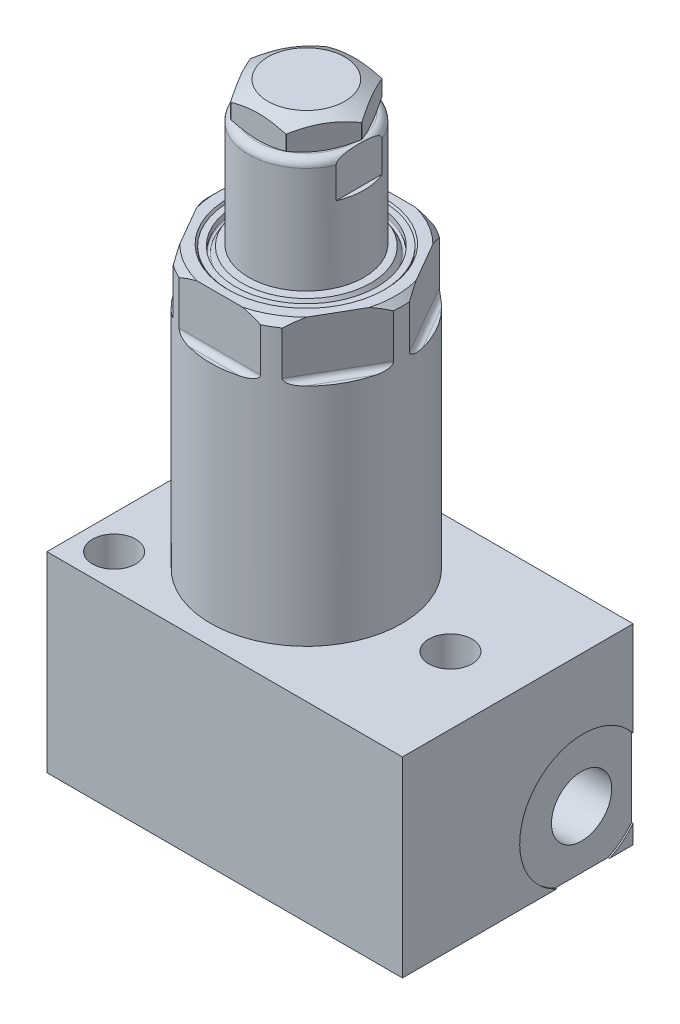
from build123d import *

# Parameters (mm, degrees)
SKETCH2_OUTSIDE_W   = 49.918
SKETCH2_OUTSIDE_H   = 49.918
CUT_EXTRUDE1_DEPTH  = 9.144
FILLET1_R           = 0.9144
SKETCH4_W           = 0.79375
SKETCH4_H           = 6.35
CUT_EXTRUDE2_DEPTH  = 11.1125
SKETCH5_W           = 4.6736
SKETCH5_H           = 6.35
SKETCH8_OUTSIDE_W   = 54.03
SKETCH8_OUTSIDE_H   = 54.03
CUT_EXTRUDE3_DEPTH  = 4.7752
SKETCH9_W           = 58.7248
SKETCH9_H           = 31.623
BOSS_EXTRUDE1_DEPTH = 19.05
SKETCH10_R          = 3.5687
CUT_EXTRUDE4_DEPTH  = 38.1
SKETCH11_R          = 10.4775
CUT_EXTRUDE5_DEPTH  = 0.254
SKETCH12_R          = 4.9784
CUT_EXTRUDE6_DEPTH  = 8.89
SKETCH14_R          = 7.9375
CUT_EXTRUDE7_DEPTH  = 2.667
SKETCH15_R          = 3.4544
CUT_EXTRUDE8_DEPTH  = 10.0076


with BuildPart() as part:
    # Sketch1 → Revolve1 (revolve)
    with BuildSketch(Plane.XY):
        with BuildLine():
            Line((9.4615, 0), (10.5918, 0))
            Line((10.5918, 0), (10.9728, 0.381))
            Line((10.9728, 0.381), (14.1097, 0.381))
            Line((14.1097, 0.381), (14.8717, 1.143))
            Line((14.8717, 1.143), (14.8717, 8.3058))
            Line((14.8717, 8.3058), (15.7988, 9.2329))
            Line((15.7988, 9.2329), (15.7988, 66.802))
            Line((15.7988, 66.802), (14.7828, 67.818))
            Line((14.7828, 67.818), (12.993293937, 67.818))
            Line((12.993293937, 67.818), (12.7, 67.31))
            Line((12.7, 67.31), (12.7, 67.5386))
            Line((12.7, 67.5386), (11.684, 67.5386))
            Line((11.684, 67.5386), (11.684, 66.6496))
            ThreePointArc((11.684, 66.6496), (11.495740037, 66.40425484), (11.210029547, 66.5226))
            Line((11.210029547, 66.5226), (10.623441674, 67.5386))
            Line((10.623441674, 67.5386), (0, 67.5386))
            Line((0, 67.5386), (0, 5.1308))
            Line((0, 5.1308), (2.3876, 5.1308))
            Line((2.3876, 5.1308), (2.3876, 1.3208))
            Line((2.3876, 1.3208), (8.5725, 1.3208))
            ThreePointArc((8.5725, 1.3208), (7.943882072, -0.196817928), (9.4615, 0.4318))
            Line((9.4615, 0.4318), (9.4615, 0))
        make_face()
    revolve(axis=Axis((0, 0, 0), (0, 1, 0)))

    # Sketch2 outside → Cut-Extrude1 (cut)
    with BuildSketch(Plane(origin=(0, 67.818, 0), x_dir=(1, 0, 0), z_dir=(0, 1, 0))):
        Rectangle(SKETCH2_OUTSIDE_W, SKETCH2_OUTSIDE_H)
        Polygon((16.497783942, 0), (8.248891971, 14.2875), (-8.248891971, 14.2875), (-16.497783942, 0), (-8.248891971, -14.2875), (8.248891971, -14.2875), align=None, mode=Mode.SUBTRACT)
    extrude(amount=-CUT_EXTRUDE1_DEPTH, mode=Mode.SUBTRACT)

    # Fillet1
    fillet1_edges = [part.edges().sort_by_distance(p)[0] for p in [
        (-12.373337957, 58.674, -7.14375),
        (0, 58.674, -14.2875),
        (12.373337957, 58.674, -7.14375),
        (12.373337957, 58.674, 7.14375),
        (0, 58.674, 14.2875),
        (-12.373337957, 58.674, 7.14375),
    ]]
    fillet(fillet1_edges, radius=FILLET1_R)

    # Sketch9 → Boss-Extrude1 (add, symmetric)
    with BuildSketch(Plane.XY):
        with Locations((5.5626, 5.6261)):
            Rectangle(SKETCH9_W, SKETCH9_H)
    extrude(amount=BOSS_EXTRUDE1_DEPTH, both=True)

    # Sketch10 → Cut-Extrude4 (cut)
    with BuildSketch(Plane(origin=(0, 21.4376, 0), x_dir=(1, 0, 0), z_dir=(0, 1, 0))):
        with Locations(Location((-18.2626, 13.4874, 0), (0, 0, 270))):  # turned: the seam where the file's is
            Circle(SKETCH10_R)
        with Locations(Location((-18.2626, -13.4874, 0), (0, 0, 270))):  # turned: the seam where the file's is
            Circle(SKETCH10_R)
        with Locations(Location((23.7998, 0, 0), (0, 0, 270))):  # turned: the seam where the file's is
            Circle(SKETCH10_R)
    extrude(amount=-CUT_EXTRUDE4_DEPTH, mode=Mode.SUBTRACT)

    # Sketch11 → Cut-Extrude5 (cut)
    with BuildSketch(Plane(origin=(34.925, 0, 0), x_dir=(0, 0, -1), z_dir=(1, 0, 0))):
        with Locations((10.795, -0.6604)):
            Circle(SKETCH11_R)
    extrude(amount=-CUT_EXTRUDE5_DEPTH, mode=Mode.SUBTRACT)

    # Sketch12 → Cut-Extrude6 (cut)
    with BuildSketch(Plane(origin=(34.671, 0, 0), x_dir=(0, 0, -1), z_dir=(1, 0, 0))):
        with Locations((10.795, -0.6604)):
            Circle(SKETCH12_R)
    extrude(amount=-CUT_EXTRUDE6_DEPTH, mode=Mode.SUBTRACT)

    # Sketch14 → Cut-Extrude7 (cut)
    with BuildSketch(Plane.XZ.offset(10.1854)):
        with Locations(Location((0, 0, 0), (0, 0, 270))):  # turned: the seam where the file's is
            Circle(SKETCH14_R)
    extrude(amount=-CUT_EXTRUDE7_DEPTH, mode=Mode.SUBTRACT)

    # Sketch15 → Cut-Extrude8 (cut)
    with BuildSketch(Plane.XZ.offset(7.5184)):
        with Locations(Location((0, 0, 0), (0, 0, 270))):  # turned: the seam where the file's is
            Circle(SKETCH15_R)
    extrude(amount=-CUT_EXTRUDE8_DEPTH, mode=Mode.SUBTRACT)


with BuildPart() as body_2:
    # Sketch3 → Revolve2 (revolve)
    with BuildSketch(Plane.XY):
        with BuildLine():
            Line((0, 67.818), (0, 86.6394))
            Line((0, 86.6394), (8.255, 86.6394))
            ThreePointArc((8.255, 86.6394), (9.153025612, 86.267425612), (9.525, 85.3694))
            Line((9.525, 85.3694), (9.525, 67.818))
            Line((9.525, 67.818), (0, 67.818))
        make_face()
    revolve(axis=Axis((0, 43.688, 0), (0, 1, 0)))

    # Sketch4 → Cut-Extrude2 (cut, symmetric)
    with BuildSketch(Plane.XY):
        with Locations((-9.128125, 83.4644)):
            Rectangle(SKETCH4_W, SKETCH4_H)
        with Locations((9.128125, 83.4644)):
            Rectangle(SKETCH4_W, SKETCH4_H)
    extrude(amount=CUT_EXTRUDE2_DEPTH, both=True, mode=Mode.SUBTRACT)

    # Sketch5 → 7_16-14 Tapped Hole1 (revolve, cut)
    with BuildSketch(Plane(origin=(0, 86.6394, 0), x_dir=(0, 0, 1), z_dir=(1, 0, 0))):
        with Locations((2.3368, 3.175)):
            Rectangle(SKETCH5_W, SKETCH5_H)
    revolve(axis=Axis((0, 92.9894, 0), (0, -1, 0)), mode=Mode.SUBTRACT)

    # Sketch7 → Revolve3 (revolve)
    with BuildSketch(Plane.XY):
        Polygon((0, 91.4146), (6.35, 91.4146), (9.144, 89.801483348), (9.144, 87.3359731), (7.9375, 86.6394), (0, 86.6394), align=None)
    revolve(axis=Axis((0, 0, 0), (0, -1, 0)))

    # Sketch8 outside → Cut-Extrude3 (cut)
    with BuildSketch(Plane(origin=(0, 91.4146, 0), x_dir=(1, 0, 0), z_dir=(0, 1, 0))):
        Rectangle(SKETCH8_OUTSIDE_W, SKETCH8_OUTSIDE_H)
        Polygon((9.165435523, 0), (4.582717762, 7.9375), (-4.582717762, 7.9375), (-9.165435523, 0), (-4.582717762, -7.9375), (4.582717762, -7.9375), align=None, mode=Mode.SUBTRACT)
    extrude(amount=-CUT_EXTRUDE3_DEPTH, mode=Mode.SUBTRACT)


solid = Compound([part.part, body_2.part])
